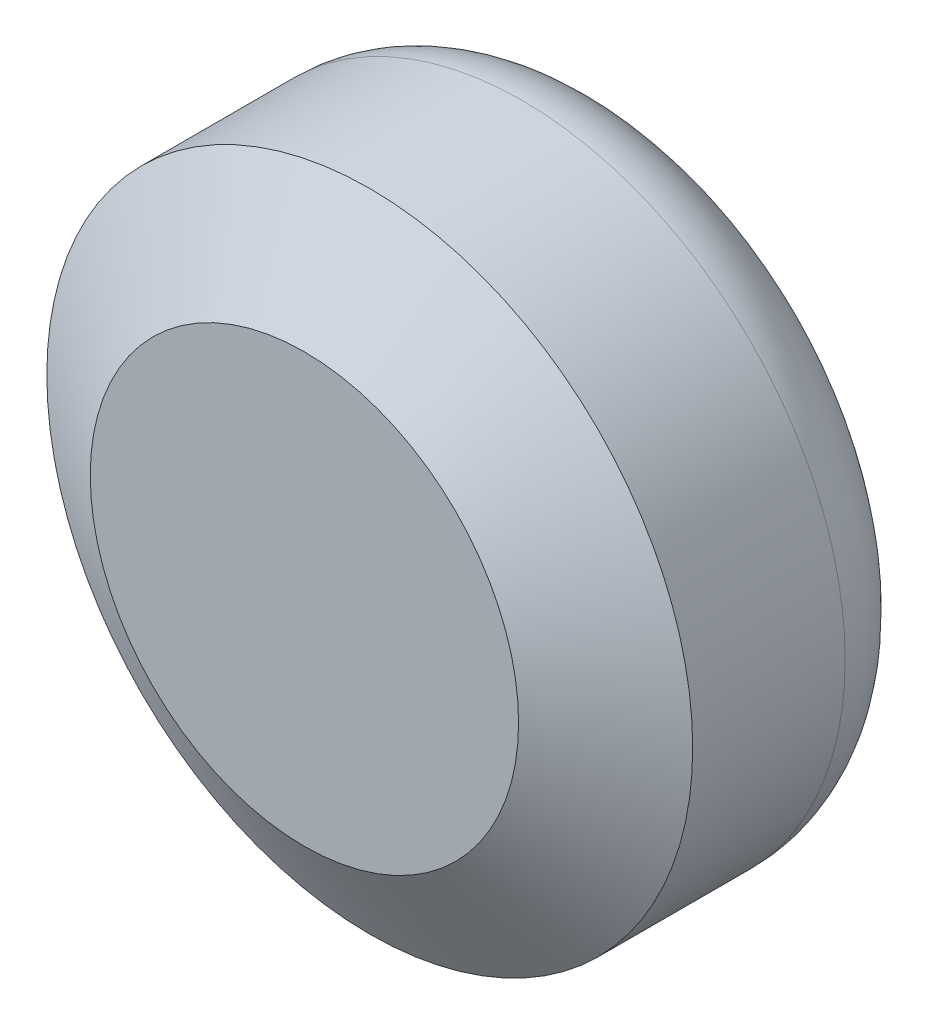
from build123d import *

# Parameters (mm, degrees)
SKETCH_1_R      = 29.65
EXTRUDE_1_DEPTH = 28
CHAMFER_1_SIZE  = 6
CHAMFER_1_SIZE2 = 9.985676894
FILLET_1_R      = 8


with BuildPart() as part:
    # 草图1 → 凸台-拉伸1 (new body)
    with BuildSketch(Plane.XY):
        with Locations((-35.577730584, 22.622481005)):
            Circle(SKETCH_1_R)
    extrude(amount=EXTRUDE_1_DEPTH)

    # 倒角1
    chamfer_1_edges = [part.edges().sort_by_distance(p)[0] for p in [
        (-65.227730584, 22.622481005, 28),
    ]]
    chamfer_1_side = [part.faces().sort_by_distance(p)[0] for p in [
        (-65.227730584, 22.622481005, 14),
    ]]
    chamfer(chamfer_1_edges, length=CHAMFER_1_SIZE, length2=CHAMFER_1_SIZE2, reference=chamfer_1_side[0])

    # 圆角1
    fillet_1_edges = [part.edges().sort_by_distance(p)[0] for p in [
        (-65.227730584, 22.622481005, 0),
    ]]
    fillet(fillet_1_edges, radius=FILLET_1_R)


solid = part.part
